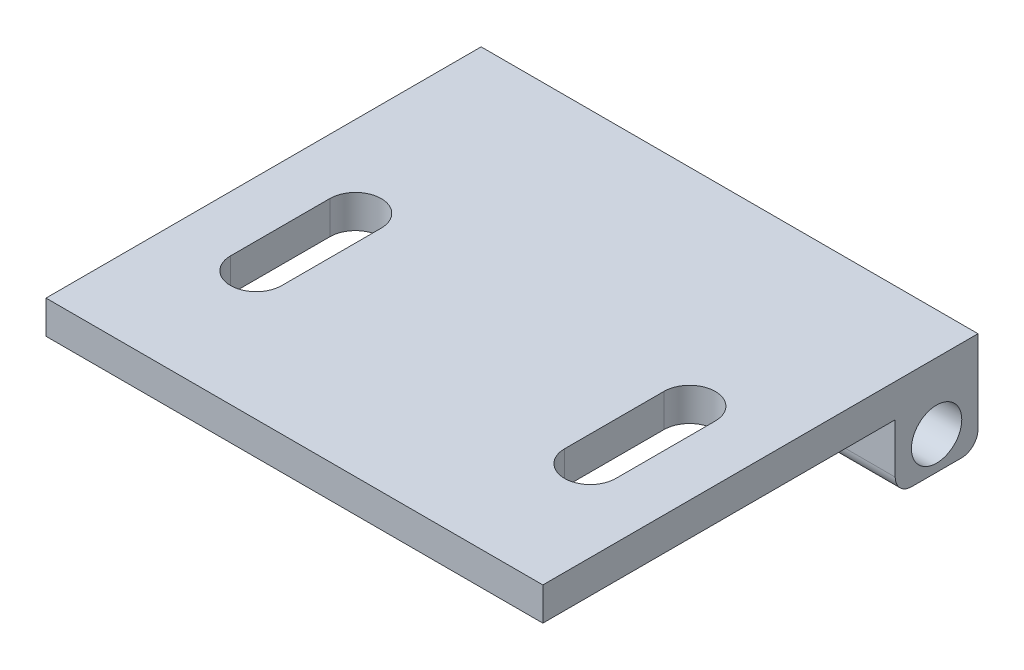
from build123d import *

# Parameters (mm, degrees)
SKIZZE5_R                       = 1.52
AUFSATZ_LINEAR_AUSTRAGEN3_DEPTH = 30
SCHNITT_LINEAR_AUSTRAGEN1_DEPTH = 10


with BuildPart() as part:
    # Skizze5 → Aufsatz-Linear austragen3 (new body)
    with BuildSketch(Plane(origin=(0, 0, 0), x_dir=(0, 0, -1), z_dir=(1, 0, 0))):
        with BuildLine():
            Line((-11.555611309, 6.111130946), (-11.555611309, 4.111130946))
            Line((-11.555611309, 4.111130946), (9.717875997, 4.111130946))
            Line((9.717875997, 4.111130946), (9.717875997, 1.111130946))
            ThreePointArc((9.717875997, 1.111130946), (10.010769216, 0.404024165), (10.717875997, 0.111130946))
            Line((10.717875997, 0.111130946), (13.717875997, 0.111130946))
            ThreePointArc((13.717875997, 0.111130946), (14.424982778, 0.404024165), (14.717875997, 1.111130946))
            Line((14.717875997, 1.111130946), (14.717875997, 6.111130946))
            Line((14.717875997, 6.111130946), (14.217875997, 6.111130946))
            Line((14.217875997, 6.111130946), (-11.555611309, 6.111130946))
        make_face()
        with Locations((12.217875997, 2.111130946)):
            Circle(SKIZZE5_R, mode=Mode.SUBTRACT)
    extrude(amount=AUFSATZ_LINEAR_AUSTRAGEN3_DEPTH)

    # Skizze6 → Schnitt-Linear austragen1 (cut)
    with BuildSketch(Plane(origin=(0, 6.111130946, 0), x_dir=(1, 0, 0), z_dir=(0, 1, 0))):
        with BuildLine():
            Line((3.364391914, -3.782124003), (3.364391914, 2.217875997))
            ThreePointArc((3.364391914, 2.217875997), (4.914391914, 3.767875997), (6.464391914, 2.217875997))
            Line((6.464391914, 2.217875997), (6.464391914, -3.782124003))
            ThreePointArc((6.464391914, -3.782124003), (4.914391914, -5.332124003), (3.364391914, -3.782124003))
        make_face()
        with BuildLine():
            Line((26.635608086, -3.782124003), (26.635608086, 2.217875997))
            ThreePointArc((26.635608086, 2.217875997), (25.085608086, 3.767875997), (23.535608086, 2.217875997))
            Line((23.535608086, 2.217875997), (23.535608086, -3.782124003))
            ThreePointArc((23.535608086, -3.782124003), (25.085608086, -5.332124003), (26.635608086, -3.782124003))
        make_face()
    extrude(amount=-SCHNITT_LINEAR_AUSTRAGEN1_DEPTH, mode=Mode.SUBTRACT)


solid = part.part
